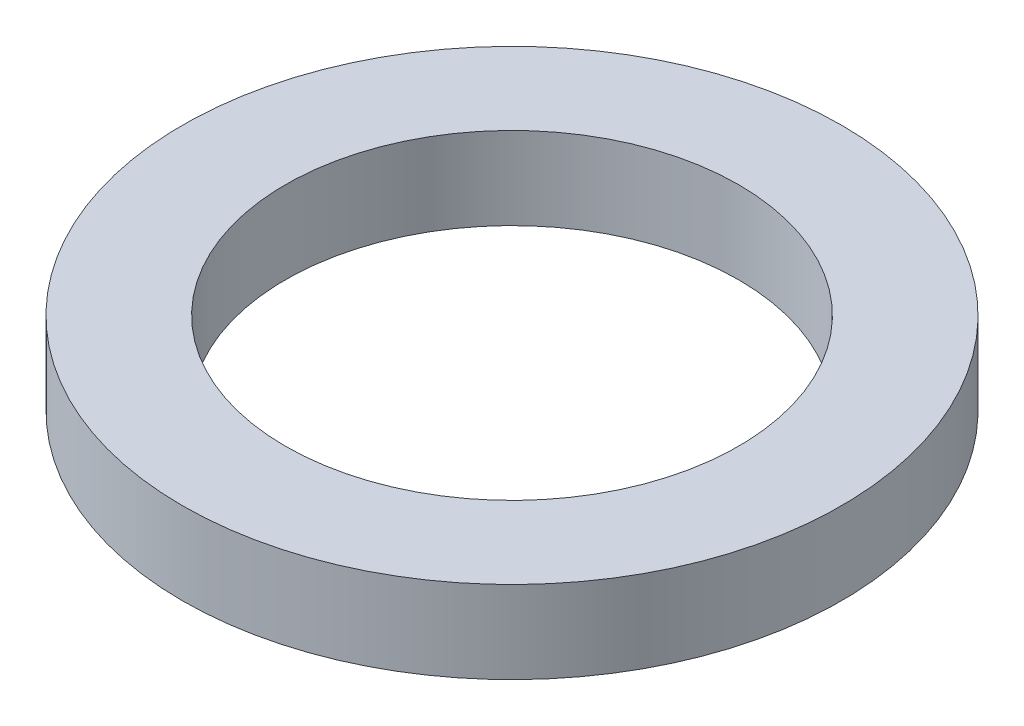
from build123d import *

# Parameters (mm, degrees)
SKETCH1_R           = 4
SKETCH1_R_2         = 2.75
BOSS_EXTRUDE1_DEPTH = 1


with BuildPart() as part:
    # Sketch1 → Boss-Extrude1 (new body)
    with BuildSketch(Plane(origin=(0, 0, 0), x_dir=(1, 0, 0), z_dir=(0, 1, 0))):
        Circle(SKETCH1_R)
        Circle(SKETCH1_R_2, mode=Mode.SUBTRACT)
    extrude(amount=BOSS_EXTRUDE1_DEPTH)


solid = part.part
